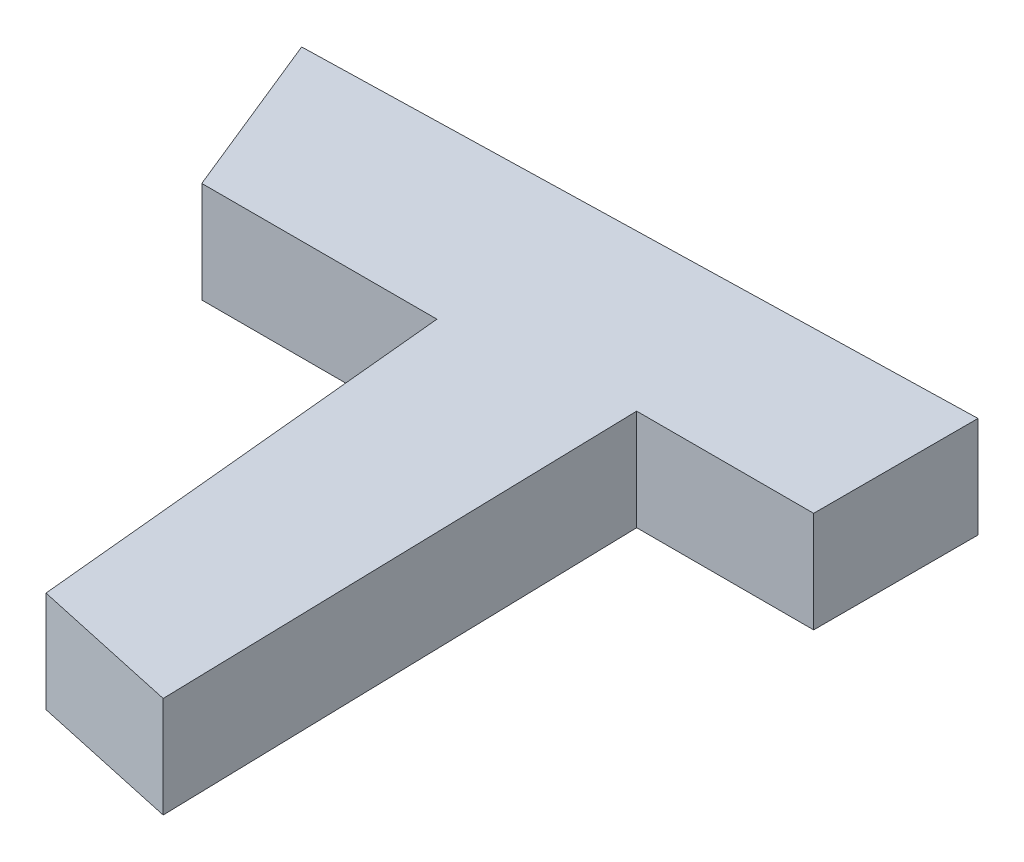
from build123d import *

# Parameters (mm, degrees)
BOSS_EXTRUDE1_DEPTH = 10


with BuildPart() as part:
    # Sketch1 → Boss-Extrude1 (new body)
    with BuildSketch(Plane(origin=(0, 0, 0), x_dir=(1, 0, 0), z_dir=(0, 1, 0))):
        Polygon((0, 0), (65.351190409, 1.627520068), (65.351190409, -14.647680609), (47.824051219, -14.647680609), (49.021651653, -62.735944196), (34.177541229, -59.495149555), (30.046524326, -16.650782231), (6.760467973, -16.650782231), align=None)
    extrude(amount=BOSS_EXTRUDE1_DEPTH)


solid = part.part
